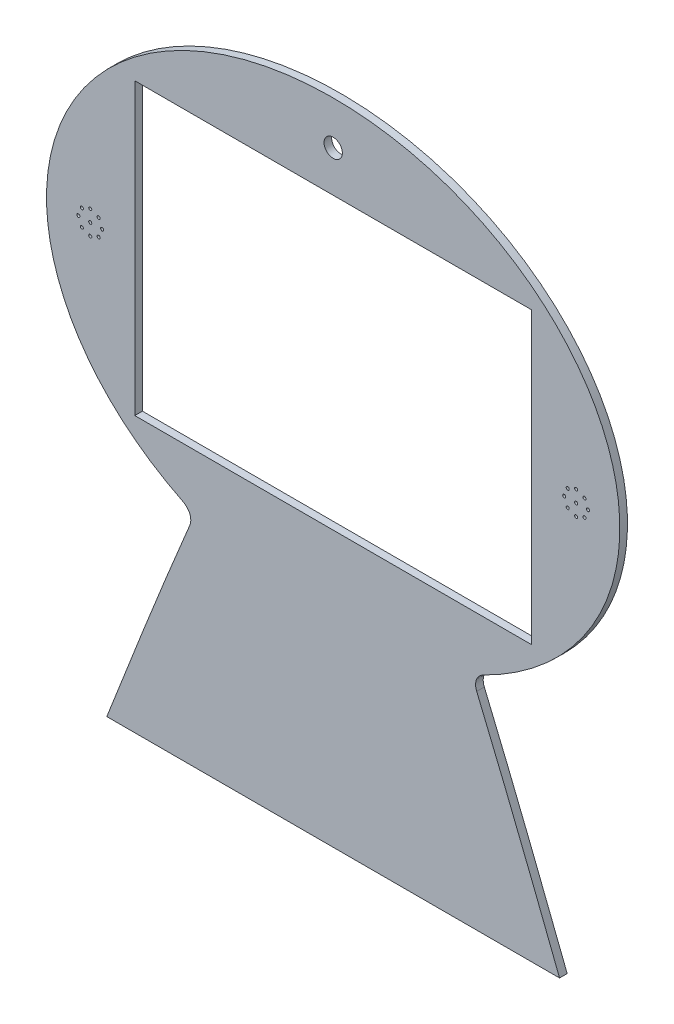
from build123d import *

# Parameters (mm, degrees)
BOSS_EXTRUDE1_DEPTH = 5
SKETCH2_W           = 260
SKETCH2_H           = 190
CUT_EXTRUDE1_DEPTH  = 5
SKETCH3_R           = 6
SKETCH3_R_2         = 1
CUT_EXTRUDE2_DEPTH  = 10


with BuildPart() as part:
    # Sketch1 → Boss-Extrude1 (new body)
    with BuildSketch(Plane.XY):
        with BuildLine():
            Line((-148.338085742, -275), (148.338085742, -275))
            add(Edge.make_bspline(
                [(94.03465926, -139.482664848), (98.755398327, -150.692304451), (103.402034194, -161.937255857), (112.5949345, -184.470591803), (117.139914862, -195.757081209), (130.666182347, -229.658400511), (139.541249416, -252.314136609), (148.338085742, -275)],
                knots=[0, 0, 0, 0, 0.25, 0.25, 0.5, 0.5, 1, 1, 1, 1], degree=3))
            add(Edge.make_bspline(
                [(94.03465926, -139.482664848), (93.807897677, -138.944207717), (93.632228084, -138.393289891), (93.44873156, -137.547400236), (93.400968388, -137.262168356), (93.333753382, -136.684799815), (93.314457185, -136.391806458), (93.301758514, -135.522101075), (93.352132982, -134.948413651), (93.51702714, -134.097168202), (93.587294467, -133.813901811), (93.757441542, -133.255425384), (93.856381915, -132.982858352), (94.192894102, -132.184252189), (94.469885532, -131.6771774), (95.126329615, -130.712320783), (95.498556449, -130.265762296), (96.110160569, -129.651415743), (96.323277646, -129.455494098), (96.767526207, -129.080908537), (96.999250674, -128.901911644), (97.711519847, -128.397088639), (98.211509615, -128.100827306), (98.734930125, -127.842108733)],
                knots=[0, 0, 0, 0, 0.125, 0.125, 0.1875, 0.1875, 0.25, 0.25, 0.375, 0.375, 0.4375, 0.4375, 0.5, 0.5, 0.625, 0.625, 0.75, 0.75, 0.8125, 0.8125, 0.875, 0.875, 1, 1, 1, 1], degree=3))
            add(Edge.make_bspline(
                [(98.734930125, -127.842108733), (106.672223721, -123.918828624), (114.353361983, -119.473544824), (123.594101635, -113.181925324), (126.339083803, -111.238929255), (129.041408633, -109.209004341), (130.83324791, -107.835932391), (131.724248955, -107.139509635), (136.133702747, -103.623593351), (139.532553379, -100.690140508), (146.065441899, -94.574866016), (149.199514814, -91.393077219), (155.189707409, -84.768806302), (158.045890694, -81.32638384), (162.106430118, -75.952907828), (163.422591833, -74.126717122), (165.338231457, -71.332467152), (165.967889958, -70.390507048), (167.202089162, -68.495669088), (167.806530157, -67.543034339), (170.765418177, -62.753771896), (172.930267822, -58.839023748), (176.84923427, -50.840291802), (178.603392437, -46.756325047), (181.685215692, -38.412662144), (183.012968812, -34.153002268), (184.664324958, -27.623308391), (185.157967349, -25.423336289), (185.809634157, -22.086790898), (186.011700844, -20.969970908), (186.383269117, -18.739871397), (186.553135224, -17.624771796), (187.323504604, -12.049026534), (188.051706383, -3.126254682), (187.787623664, 5.799624386), (187.214676295, 12.495207594), (186.961121479, 14.7272646), (186.485726865, 18.075647787), (186.311412137, 19.191825148), (185.930806376, 21.424279999), (185.724312725, 22.541306074), (184.618654926, 28.091354383), (183.496220522, 32.446699946), (180.802610969, 40.997643559), (179.231349123, 45.193210746), (176.548966571, 51.370690205), (175.600504309, 53.410507363), (174.096972318, 56.441455315), (173.582316995, 57.446973259), (172.526103033, 59.448431819), (171.984021799, 60.445248111), (169.219962954, 65.381742276), (166.829282669, 69.195376687), (161.715727573, 76.571674152), (158.992763546, 80.134269804), (153.231632217, 87.021326558), (150.193416088, 90.345750773), (146.204645913, 94.356981454), (145.397721818, 95.151563896), (143.771334443, 96.720280652), (141.310675208, 99.044978255), (138.788120469, 101.28634599), (133.663539484, 105.66208903), (130.141333571, 108.436787571), (122.897332622, 113.717477966), (119.175504713, 116.223425565), (113.448691256, 119.788383487), (111.51570962, 120.944332622), (107.602245868, 123.192281032), (105.619199648, 124.285533164), (95.646909406, 129.562031056), (87.451362285, 133.202583938), (70.666231248, 139.43279408), (62.076345804, 142.021647163), (51.099809039, 144.61982087), (48.891485501, 145.107485881), (44.476604411, 146.013685071), (42.266898023, 146.433010245), (35.631114178, 147.59164273), (31.198381042, 148.231741166), (17.874264573, 149.765719495), (8.957092466, 150.275194595), (-4.469912765, 150.275523724), (-8.954154708, 150.14783725), (-15.693628409, 149.760879524), (-17.943175049, 149.599214758), (-22.44311872, 149.209966108), (-24.684580548, 148.983180383), (-35.849720493, 147.689884073), (-44.647543981, 146.147738071), (-61.973779364, 142.045273806), (-70.50229306, 139.485340268), (-83.079153043, 134.82946117), (-87.235309424, 133.14095631), (-92.382550742, 130.849094747), (-93.409597112, 130.381645094), (-95.458798541, 129.428260322), (-96.480834957, 128.942354293), (-99.527797872, 127.46220511), (-101.537495886, 126.443743321), (-111.477123597, 121.191768933), (-119.082672116, 116.482495353), (-129.93118937, 108.597533563), (-133.45364095, 105.831755182), (-138.5869234, 101.462507505), (-140.272913555, 99.969272271), (-143.592518731, 96.905984629), (-145.229309992, 95.332565098), (-150.017994844, 90.531821869), (-153.057609061, 87.216733744), (-158.821891154, 80.350428358), (-161.546605709, 76.799246094), (-166.66454997, 69.448352783), (-169.057865382, 65.648705992), (-171.826218331, 60.731736176), (-172.368697643, 59.739951619), (-173.43075339, 57.739211209), (-173.951056006, 56.728751656), (-175.468931799, 53.686928321), (-176.424904194, 51.642861807), (-179.125229254, 45.462179476), (-180.702315549, 41.27717511), (-183.403816096, 32.776212716), (-184.528276879, 28.46026815), (-186.307182147, 19.69240783), (-186.961728504, 15.240521547), (-187.467123424, 9.58517713), (-187.552402564, 8.45050895), (-187.690612448, 6.18217062), (-187.796693469, 3.912502375), (-187.838454188, 1.640171713), (-187.847973635, -0.633493517), (-187.836652426, -1.761085094), (-187.701266627, -7.395776285), (-187.34092428, -11.858860476), (-186.136744198, -20.699337387), (-185.292848212, -25.076719781), (-183.670534578, -31.579615088), (-183.070261869, -33.736701211), (-182.080588364, -36.956509766), (-181.735814369, -38.027141552), (-181.016433358, -40.163117721), (-180.641402271, -41.229608891), (-178.696302608, -46.535485041), (-176.929269355, -50.663442598), (-173.003479768, -58.70257503), (-170.844620918, -62.613693172), (-166.153835391, -70.229470742), (-163.621854753, -73.934100308), (-160.229794561, -78.439216947), (-159.539495177, -79.334555859), (-158.142352572, -81.105078347), (-157.434871203, -81.981140567), (-155.286277529, -84.582329617), (-153.819031706, -86.280475405), (-149.316764675, -91.271122983), (-146.181416277, -94.460043922), (-139.658902036, -100.577901787), (-136.271690727, -103.506791774), (-131.009344272, -107.71271017), (-129.224931494, -109.083403119), (-125.596270465, -111.763013049), (-123.758491931, -113.067071632), (-114.479495371, -119.39878308), (-106.746494591, -123.882117694), (-98.734930125, -127.842108733)],
                knots=[0, 0, 0, 0, 0.03125, 0.03125, 0.0390625, 0.04296875, 0.04296875, 0.046875, 0.046875, 0.0625, 0.0625, 0.078125, 0.078125, 0.09375, 0.09375, 0.1015625, 0.1015625, 0.10546875, 0.10546875, 0.109375, 0.109375, 0.125, 0.125, 0.140625, 0.140625, 0.15625, 0.15625, 0.1640625, 0.1640625, 0.16796875, 0.16796875, 0.171875, 0.171875, 0.1875, 0.203125, 0.203125, 0.2109375, 0.2109375, 0.21484375, 0.21484375, 0.21875, 0.21875, 0.234375, 0.234375, 0.25, 0.25, 0.2578125, 0.2578125, 0.26171875, 0.26171875, 0.265625, 0.265625, 0.28125, 0.28125, 0.296875, 0.296875, 0.3125, 0.3125, 0.31640625, 0.31640625, 0.3203125, 0.328125, 0.328125, 0.34375, 0.34375, 0.359375, 0.359375, 0.3671875, 0.3671875, 0.375, 0.375, 0.40625, 0.40625, 0.4375, 0.4375, 0.4453125, 0.4453125, 0.453125, 0.453125, 0.46875, 0.46875, 0.5, 0.5, 0.515625, 0.515625, 0.5234375, 0.5234375, 0.53125, 0.53125, 0.5625, 0.5625, 0.59375, 0.59375, 0.609375, 0.609375, 0.61328125, 0.61328125, 0.6171875, 0.6171875, 0.625, 0.625, 0.65625, 0.65625, 0.671875, 0.671875, 0.6796875, 0.6796875, 0.6875, 0.6875, 0.703125, 0.703125, 0.71875, 0.71875, 0.734375, 0.734375, 0.73828125, 0.73828125, 0.7421875, 0.7421875, 0.75, 0.75, 0.765625, 0.765625, 0.78125, 0.78125, 0.796875, 0.796875, 0.80078125, 0.80078125, 0.8046875, 0.80859375, 0.80859375, 0.8125, 0.8125, 0.828125, 0.828125, 0.84375, 0.84375, 0.8515625, 0.8515625, 0.85546875, 0.85546875, 0.859375, 0.859375, 0.875, 0.875, 0.890625, 0.890625, 0.90625, 0.90625, 0.91015625, 0.91015625, 0.9140625, 0.9140625, 0.921875, 0.921875, 0.9375, 0.9375, 0.953125, 0.953125, 0.9609375, 0.9609375, 0.96875, 0.96875, 1, 1, 1, 1], degree=3))
            add(Edge.make_bspline(
                [(-98.734930125, -127.842108733), (-98.211290119, -128.100935799), (-97.713448362, -128.396201475), (-96.7716066, -129.062781345), (-96.326898331, -129.43465053), (-95.50125689, -130.262122999), (-95.132058379, -130.705876789), (-94.483520325, -131.655218618), (-94.203516921, -132.162102934), (-93.746863616, -133.239792933), (-93.5777887, -133.792203887), (-93.410949383, -134.640687405), (-93.369877307, -134.92684448), (-93.317418821, -135.505955296), (-93.306201453, -135.800056988), (-93.317807229, -136.672433839), (-93.384544066, -137.246799447), (-93.62877986, -138.381978258), (-93.807411936, -138.9430543), (-94.03465926, -139.482664848)],
                knots=[0, 0, 0, 0, 0.125, 0.125, 0.25, 0.25, 0.375, 0.375, 0.5, 0.5, 0.625, 0.625, 0.6875, 0.6875, 0.75, 0.75, 0.875, 0.875, 1, 1, 1, 1], degree=3))
            add(Edge.make_bspline(
                [(-148.338085742, -275), (-139.541392798, -252.314506371), (-130.666490496, -229.65918909), (-117.140535746, -195.758629224), (-112.595670785, -184.472415193), (-103.403035713, -161.93969212), (-98.755330202, -150.692142686), (-94.03465926, -139.482664848)],
                knots=[0, 0, 0, 0, 0.5, 0.5, 0.75, 0.75, 1, 1, 1, 1], degree=3))
        make_face()
    extrude(amount=BOSS_EXTRUDE1_DEPTH)

    # Sketch2 → Cut-Extrude1 (cut)
    with BuildSketch(Plane.XY.offset(5)):
        Rectangle(SKETCH2_W, SKETCH2_H)
    extrude(amount=-CUT_EXTRUDE1_DEPTH, mode=Mode.SUBTRACT)

    # Sketch3 → Cut-Extrude2 (cut)
    with BuildSketch(Plane.XY.offset(5)):
        with Locations((0, 121.959318028)):
            Circle(SKETCH3_R)
        with Locations((-159.179730943, 0)):
            Circle(SKETCH3_R_2)
        with Locations((-159.179730943, 7.787501567)):
            Circle(SKETCH3_R_2)
        with Locations((-153.673135777, 5.506595166)):
            Circle(SKETCH3_R_2)
        with Locations((-151.392229376, 0)):
            Circle(SKETCH3_R_2)
        with Locations((-153.673135777, -5.506595166)):
            Circle(SKETCH3_R_2)
        with Locations((-159.179730943, -7.787501567)):
            Circle(SKETCH3_R_2)
        with Locations((-164.686326109, -5.506595166)):
            Circle(SKETCH3_R_2)
        with Locations((-166.96723251, 0)):
            Circle(SKETCH3_R_2)
        with Locations((-164.686326109, 5.506595166)):
            Circle(SKETCH3_R_2)
        with Locations((164.686326109, 5.506595166)):
            Circle(SKETCH3_R_2)
        with Locations((166.96723251, 0)):
            Circle(SKETCH3_R_2)
        with Locations((164.686326109, -5.506595166)):
            Circle(SKETCH3_R_2)
        with Locations((159.179730943, -7.787501567)):
            Circle(SKETCH3_R_2)
        with Locations((153.673135777, -5.506595166)):
            Circle(SKETCH3_R_2)
        with Locations((151.392229376, 0)):
            Circle(SKETCH3_R_2)
        with Locations((153.673135777, 5.506595166)):
            Circle(SKETCH3_R_2)
        with Locations((159.179730943, 7.787501567)):
            Circle(SKETCH3_R_2)
        with Locations((159.179730943, 0)):
            Circle(SKETCH3_R_2)
    extrude(amount=-CUT_EXTRUDE2_DEPTH, mode=Mode.SUBTRACT)


solid = part.part
